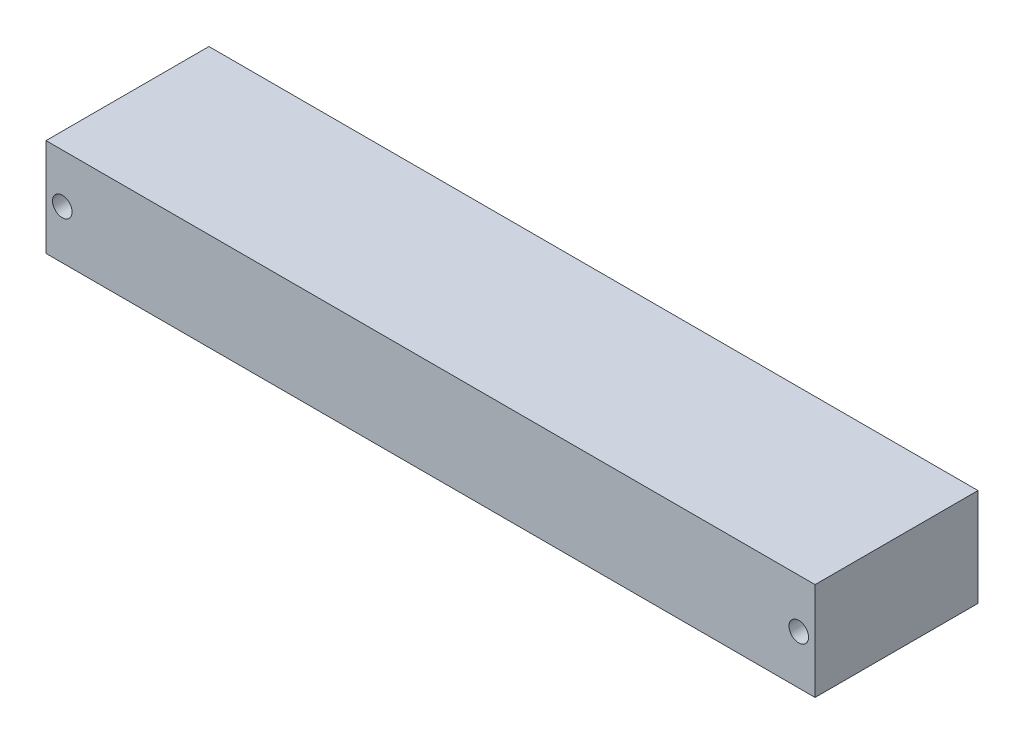
from build123d import *

# Parameters (mm, degrees)
SKETCH1_W           = 118
SKETCH1_H           = 25
BOSS_EXTRUDE1_DEPTH = 15
SKETCH3_R           = 1.5
CUT_EXTRUDE1_DEPTH  = 37


with BuildPart() as part:
    # Sketch1 → Boss-Extrude1 (new body)
    with BuildSketch(Plane(origin=(0, 0, 0), x_dir=(1, 0, 0), z_dir=(0, 1, 0))):
        Rectangle(SKETCH1_W, SKETCH1_H)
    extrude(amount=BOSS_EXTRUDE1_DEPTH)

    # Sketch3 → Cut-Extrude1 (cut)
    with BuildSketch(Plane.XY.offset(12.5)):
        with Locations((-56.5, 7.5)):
            Circle(SKETCH3_R)
        with Locations((56.5, 7.5)):
            Circle(SKETCH3_R)
    extrude(amount=-CUT_EXTRUDE1_DEPTH, mode=Mode.SUBTRACT)


solid = part.part
